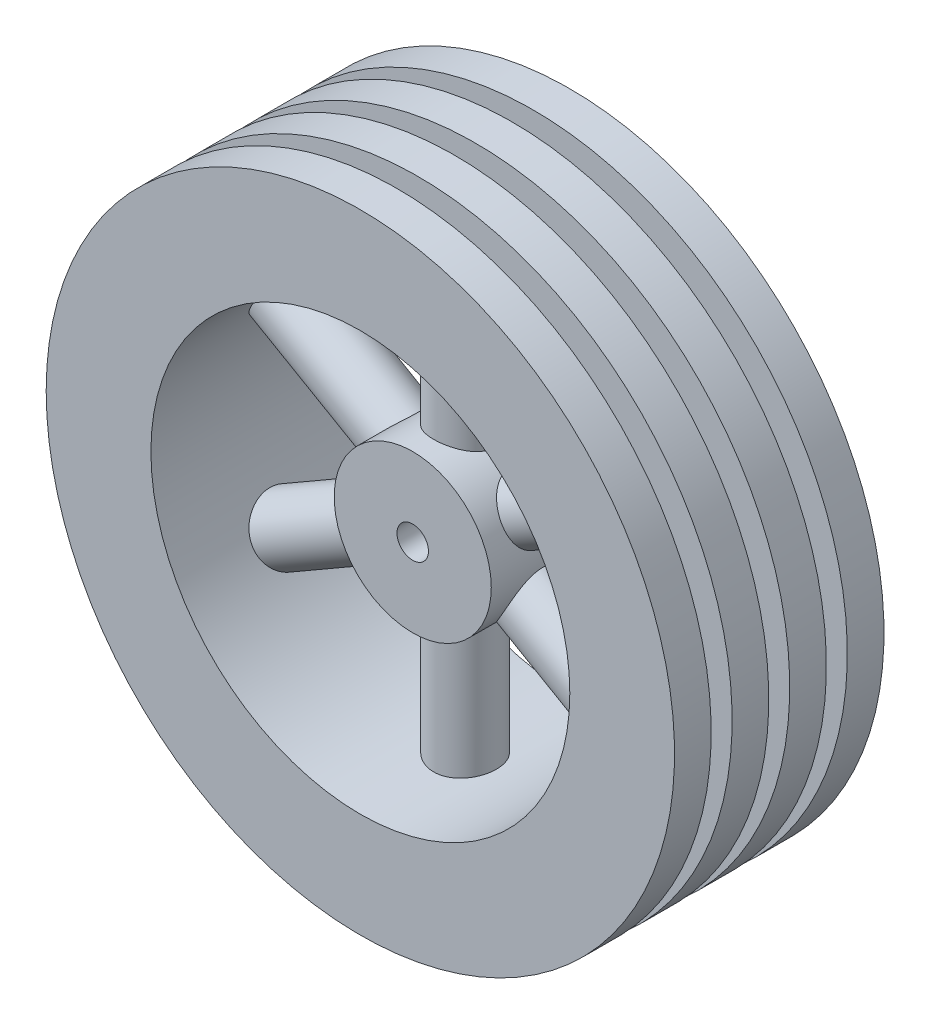
from build123d import *

# Parameters (mm, degrees)
SKETCH_1_R               = 7.5
SKETCH_1_R_2             = 1.5
EXTRUDE_1_DEPTH          = 20
EXTRUDE_START            = -5.126128
SKETCH_5_R               = 3
EXTRUDE_3_DEPTH          = 13.126128
PATTERN_CIRCULAR_1_COUNT = 6
SKETCH_6_R               = 7.5
CUT_EXTRUDE_1_DEPTH      = 5


with BuildPart() as part:
    # 草圖1 → 填料-伸長1 (new body)
    with BuildSketch(Plane.XY):
        Circle(SKETCH_1_R)
        Circle(SKETCH_1_R_2, mode=Mode.SUBTRACT)
    extrude(amount=EXTRUDE_1_DEPTH)



with BuildPart() as body_2:
    # 草圖2 → 旋轉2 (revolve)
    with BuildSketch(Plane(origin=(0, 0, 0), x_dir=(1, 0, 0), z_dir=(0, 1, 0))):
        Polygon((-30, 0), (-20, 0), (-20, -20), (-30, -20), (-30, -16.5), (-22.5, -16.5), (-22.5, -14.5), (-30, -14.5), (-30, -11), (-22.5, -11), (-22.5, -9), (-30, -9), (-30, -5.5), (-22.5, -5.5), (-22.5, -3.5), (-30, -3.5), align=None)
    revolve(axis=Axis((0, 0, -16.060558383), (0, 0, 1)))


with BuildPart() as part_1:
    add(part.part)

    add(body_2.part)  # 填料-伸長3 merges body 2
    # 草圖5 → 填料-伸長3 (add)
    with BuildSketch(Plane(origin=(0, 12, 0), x_dir=(1, 0, 0), z_dir=(0, 1, 0)).offset(EXTRUDE_START)):
        with Locations((0, -10)):
            Circle(SKETCH_5_R)
    extrude_3 = extrude(amount=EXTRUDE_3_DEPTH)

    # 環狀複製排列1: 填料-伸長3 ×6 about axis
    pattern_circular_1_axis = Axis((0, 0, 20), (0, 0, -1))
    for i in range(1, PATTERN_CIRCULAR_1_COUNT):
        add(extrude_3.rotate(pattern_circular_1_axis, i * 360 / PATTERN_CIRCULAR_1_COUNT))

    # 草圖6 → 除料-伸長1 (cut)
    with BuildSketch(Plane.XY.offset(20)):
        Circle(SKETCH_6_R)
    extrude(amount=-CUT_EXTRUDE_1_DEPTH, mode=Mode.SUBTRACT)


solid = part_1.part
